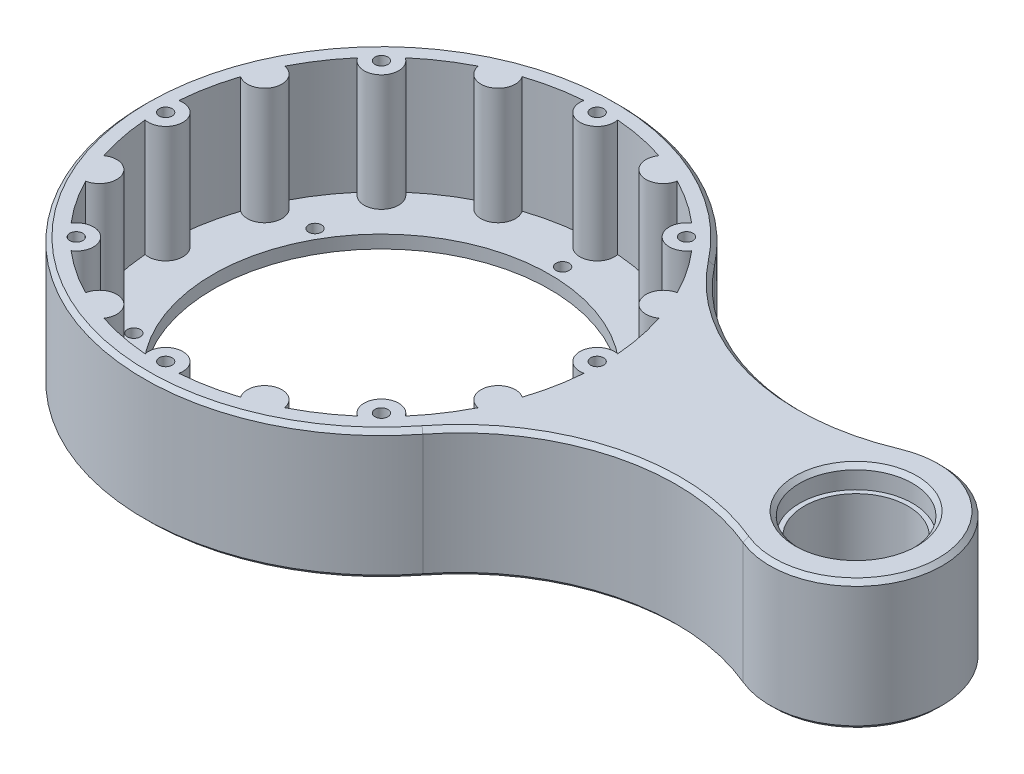
from build123d import *

# Parameters (mm, degrees)
SKETCH1_R           = 55
SKETCH1_R_2         = 39
SKETCH1_R_3         = 1.5
BOSS_EXTRUDE1_DEPTH = 3
SKETCH2_R           = 55
SKETCH2_R_2         = 1.5
BOSS_EXTRUDE3_DEPTH = 27
BOSS_EXTRUDE4_START = -30
SKETCH3_R           = 13.1
BOSS_EXTRUDE4_DEPTH = 30
BOSS_EXTRUDE5_START = -5
SKETCH6_R           = 13.1
SKETCH6_R_2         = 12
BOSS_EXTRUDE5_DEPTH = 20
CHAMFER1_SIZE       = 1


with BuildPart() as part:
    # Sketch1 → Boss-Extrude1 (new body)
    with BuildSketch(Plane(origin=(0, 0, 0), x_dir=(1, 0, 0), z_dir=(0, 1, 0))):
        Circle(SKETCH1_R)
        Circle(SKETCH1_R_2, mode=Mode.SUBTRACT)
        with Locations((0, 50)):
            Circle(SKETCH1_R_3, mode=Mode.SUBTRACT)
        with Locations((35.355339059, 35.355339059)):
            Circle(SKETCH1_R_3, mode=Mode.SUBTRACT)
        with Locations((50, 0)):
            Circle(SKETCH1_R_3, mode=Mode.SUBTRACT)
        with Locations((35.355339059, -35.355339059)):
            Circle(SKETCH1_R_3, mode=Mode.SUBTRACT)
        with Locations((0, -50)):
            Circle(SKETCH1_R_3, mode=Mode.SUBTRACT)
        with Locations((-35.355339059, -35.355339059)):
            Circle(SKETCH1_R_3, mode=Mode.SUBTRACT)
        with Locations((-50, 0)):
            Circle(SKETCH1_R_3, mode=Mode.SUBTRACT)
        with Locations((-35.355339059, 35.355339059)):
            Circle(SKETCH1_R_3, mode=Mode.SUBTRACT)
        with Locations((0, 42)):
            Circle(SKETCH1_R_3, mode=Mode.SUBTRACT)
        with Locations((36.373066959, 21)):
            Circle(SKETCH1_R_3, mode=Mode.SUBTRACT)
        with Locations((36.373066959, -21)):
            Circle(SKETCH1_R_3, mode=Mode.SUBTRACT)
        with Locations((0, -42)):
            Circle(SKETCH1_R_3, mode=Mode.SUBTRACT)
        with Locations((-36.373066959, -21)):
            Circle(SKETCH1_R_3, mode=Mode.SUBTRACT)
        with Locations((-36.373066959, 21)):
            Circle(SKETCH1_R_3, mode=Mode.SUBTRACT)
    extrude(amount=BOSS_EXTRUDE1_DEPTH)

    # Sketch2 → Boss-Extrude3 (add)
    with BuildSketch(Plane(origin=(0, 3, 0), x_dir=(1, 0, 0), z_dir=(0, 1, 0))):
        Circle(SKETCH2_R)
        with Locations((-35.355339059, 35.355339059)):
            Circle(SKETCH2_R_2, mode=Mode.SUBTRACT)
        with Locations((-50, 0)):
            Circle(SKETCH2_R_2, mode=Mode.SUBTRACT)
        with Locations((-35.355339059, -35.355339059)):
            Circle(SKETCH2_R_2, mode=Mode.SUBTRACT)
        with Locations((0, -50)):
            Circle(SKETCH2_R_2, mode=Mode.SUBTRACT)
        with Locations((35.355339059, -35.355339059)):
            Circle(SKETCH2_R_2, mode=Mode.SUBTRACT)
        with Locations((50, 0)):
            Circle(SKETCH2_R_2, mode=Mode.SUBTRACT)
        with Locations((35.355339059, 35.355339059)):
            Circle(SKETCH2_R_2, mode=Mode.SUBTRACT)
        with Locations((0, 50)):
            Circle(SKETCH2_R_2, mode=Mode.SUBTRACT)
        with BuildLine():
            ThreePointArc((-3.908644266, 50.85), (0, 46), (3.908644266, 50.85))
            ThreePointArc((3.908644266, 50.85), (9.949606423, 50.020049301), (15.848336098, 48.475047632))
            ThreePointArc((15.848336098, 48.475047632), (17.603437889, 42.498458496), (23.070568973, 45.483500825))
            ThreePointArc((23.070568973, 45.483500825), (28.334081884, 42.404950227), (33.192550957, 38.720208689))
            ThreePointArc((33.192550957, 38.720208689), (32.526911935, 32.526911935), (38.720208689, 33.192550957))
            ThreePointArc((38.720208689, 33.192550957), (42.404950227, 28.334081884), (45.483500825, 23.070568973))
            ThreePointArc((45.483500825, 23.070568973), (42.498458496, 17.603437889), (48.475047632, 15.848336098))
            ThreePointArc((48.475047632, 15.848336098), (50.020049301, 9.949606423), (50.85, 3.908644266))
            ThreePointArc((50.85, 3.908644266), (46, 0), (50.85, -3.908644266))
            ThreePointArc((50.85, -3.908644266), (50.020049301, -9.949606423), (48.475047632, -15.848336098))
            ThreePointArc((48.475047632, -15.848336098), (42.498458496, -17.603437889), (45.483500825, -23.070568973))
            ThreePointArc((45.483500825, -23.070568973), (42.404950227, -28.334081884), (38.720208689, -33.192550957))
            ThreePointArc((38.720208689, -33.192550957), (32.526911935, -32.526911935), (33.192550957, -38.720208689))
            ThreePointArc((33.192550957, -38.720208689), (28.334081884, -42.404950227), (23.070568973, -45.483500825))
            ThreePointArc((23.070568973, -45.483500825), (17.603437889, -42.498458496), (15.848336098, -48.475047632))
            ThreePointArc((15.848336098, -48.475047632), (9.949606423, -50.020049301), (3.908644266, -50.85))
            ThreePointArc((3.908644266, -50.85), (0, -46), (-3.908644266, -50.85))
            ThreePointArc((-3.908644266, -50.85), (-9.949606423, -50.020049301), (-15.848336098, -48.475047632))
            ThreePointArc((-15.848336098, -48.475047632), (-17.603437889, -42.498458496), (-23.070568973, -45.483500825))
            ThreePointArc((-23.070568973, -45.483500825), (-28.334081884, -42.404950227), (-33.192550957, -38.720208689))
            ThreePointArc((-33.192550957, -38.720208689), (-32.526911935, -32.526911935), (-38.720208689, -33.192550957))
            ThreePointArc((-38.720208689, -33.192550957), (-42.404950227, -28.334081884), (-45.483500825, -23.070568973))
            ThreePointArc((-45.483500825, -23.070568973), (-42.498458496, -17.603437889), (-48.475047632, -15.848336098))
            ThreePointArc((-48.475047632, -15.848336098), (-50.020049301, -9.949606423), (-50.85, -3.908644266))
            ThreePointArc((-50.85, -3.908644266), (-46, 0), (-50.85, 3.908644266))
            ThreePointArc((-50.85, 3.908644266), (-50.020049301, 9.949606423), (-48.475047632, 15.848336098))
            ThreePointArc((-48.475047632, 15.848336098), (-42.498458496, 17.603437889), (-45.483500825, 23.070568973))
            ThreePointArc((-45.483500825, 23.070568973), (-42.404950227, 28.334081884), (-38.720208689, 33.192550957))
            ThreePointArc((-38.720208689, 33.192550957), (-32.526911935, 32.526911935), (-33.192550957, 38.720208689))
            ThreePointArc((-33.192550957, 38.720208689), (-28.334081884, 42.404950227), (-23.070568973, 45.483500825))
            ThreePointArc((-23.070568973, 45.483500825), (-17.603437889, 42.498458496), (-15.848336098, 48.475047632))
            ThreePointArc((-15.848336098, 48.475047632), (-9.949606423, 50.020049301), (-3.908644266, 50.85))
        make_face(mode=Mode.SUBTRACT)
    extrude(amount=BOSS_EXTRUDE3_DEPTH)

    # Sketch3 → Boss-Extrude4 (add)
    with BuildSketch(Plane(origin=(0, 30, 0), x_dir=(1, 0, 0), z_dir=(0, 1, 0)).offset(BOSS_EXTRUDE4_START)):
        with BuildLine():
            ThreePointArc((43.392857143, -33.794377476), (55, 0), (43.392857143, 33.794377476))
            ThreePointArc((43.392857143, 33.794377476), (70.212437062, 16.137600278), (102.24025974, 18.433296805))
            ThreePointArc((102.24025974, 18.433296805), (130, 0), (102.24025974, -18.433296805))
            ThreePointArc((102.24025974, -18.433296805), (70.212437062, -16.137600278), (43.392857143, -33.794377476))
        make_face()
        with Locations((110, 0)):
            Circle(SKETCH3_R, mode=Mode.SUBTRACT)
    extrude(amount=BOSS_EXTRUDE4_DEPTH)

    # Sketch6 → Boss-Extrude5 (add)
    with BuildSketch(Plane(origin=(0, 30, 0), x_dir=(1, 0, 0), z_dir=(0, 1, 0)).offset(BOSS_EXTRUDE5_START)):
        with Locations((110, 0)):
            Circle(SKETCH6_R)
        with Locations((110, 0)):
            Circle(SKETCH6_R_2, mode=Mode.SUBTRACT)
    extrude(amount=-BOSS_EXTRUDE5_DEPTH)

    # Chamfer1
    chamfer1_edges = [part.edges().sort_by_distance(p)[0] for p in [
        (-55, 30, 0),
        (-55, 0, 0),
        (130, 30, 0),
        (70.212437062, 0, -16.137600278),
        (70.212437062, 0, 16.137600278),
        (96.9, 0, 0),
        (70.212437062, 30, -16.137600278),
        (70.212437062, 30, 16.137600278),
        (130, 0, 0),
        (96.9, 30, 0),
    ]]
    chamfer(chamfer1_edges, length=CHAMFER1_SIZE)


solid = part.part
